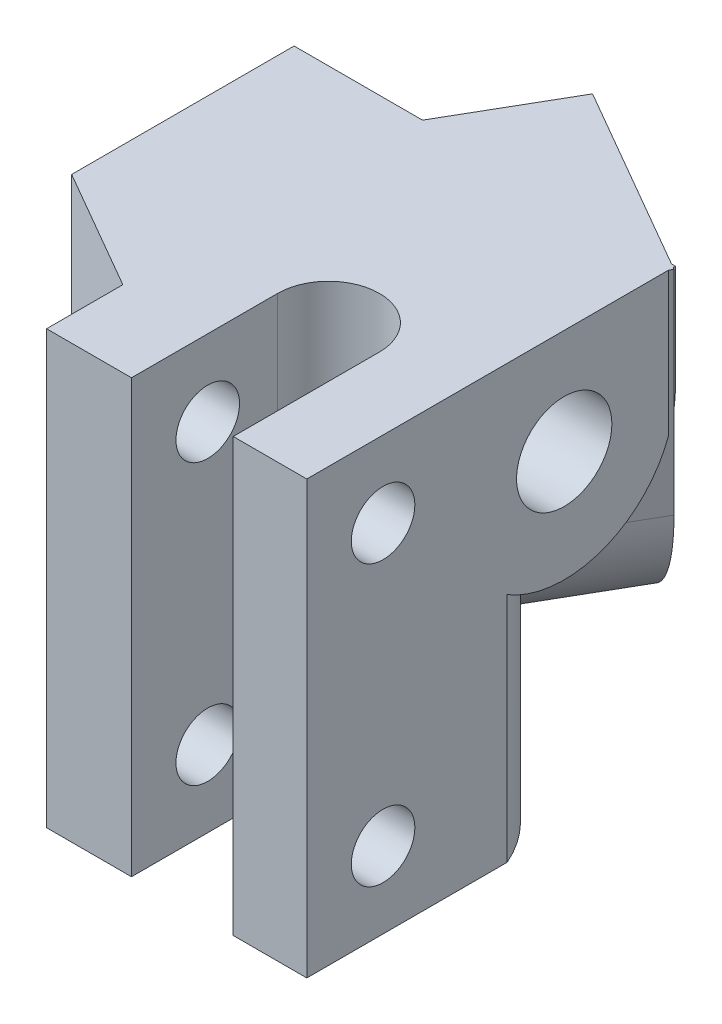
from build123d import *

# Parameters (mm, degrees)
SKETCH1_R               = 3.75
BOSS_EXTRUDE1_DEPTH     = 30
SKETCH2_R               = 3.75
BOSS_EXTRUDE2_DEPTH     = 30
CUT_EXTRUDE1_DEPTH      = 26.5000001
SKETCH4_W               = 5.792740578
SKETCH4_H               = 11.5
BOSS_EXTRUDE3_DEPTH     = 10
BOSS_EXTRUDE4_DEPTH     = 10
BOSS_EXTRUDE5_DEPTH     = 34
SKETCH5_R               = 2.5
CUT_EXTRUDE2_DEPTH      = 31.0000001
SKETCH7_R               = 3.75
CUT_EXTRUDE3_DEPTH      = 31.155444666
SKETCH8_R               = 3.75
CUT_EXTRUDE4_DEPTH      = 27.5
CUT_EXTRUDE4_DEPTH_BACK = 38.57772242


with BuildPart() as part:
    # Sketch1 → Boss-Extrude1 (new body)
    with BuildSketch(Plane(origin=(0, 0, 0), x_dir=(0, 0, -1), z_dir=(1, 0, 0))):
        with BuildLine():
            Line((-8.75, 0), (8.75, 0))
            Line((8.75, 0), (8.75, 8.25))
            ThreePointArc((8.75, 8.25), (0, 17), (-8.75, 8.25))
            Line((-8.75, 8.25), (-8.75, 0))
        make_face()
        with Locations((0, 8.25)):
            Circle(SKETCH1_R, mode=Mode.SUBTRACT)
    extrude(amount=BOSS_EXTRUDE1_DEPTH)

    # Sketch2 → Boss-Extrude2 (add)
    with BuildSketch(Plane(origin=(-3.788861142, 0, 6.5625), x_dir=(-0.866025404, 0, -0.5), z_dir=(0.5, 0, -0.866025404))):
        with BuildLine():
            Line((-4.375, 0), (-4.375, 16.75))
            ThreePointArc((-4.375, 16.75), (-13.125, 25.5), (-21.875, 16.75))
            Line((-21.875, 16.75), (-21.875, 0))
            Line((-21.875, 0), (-4.375, 0))
        make_face()
        with Locations((-13.125, 16.75)):
            Circle(SKETCH2_R, mode=Mode.SUBTRACT)
    extrude(amount=BOSS_EXTRUDE2_DEPTH)

    # Sketch3 → Cut-Extrude1 (cut, through all)
    with BuildSketch(Plane.XZ):
        with BuildLine():
            Line((24.207259422, 8.75), (24.207259422, 15.67820323))
            Line((24.207259422, 15.67820323), (16.207259422, 15.67820323))
            Line((16.207259422, 15.67820323), (16.207259422, 8.75))
            ThreePointArc((16.207259422, 8.75), (20.207259422, 4.75), (24.207259422, 8.75))
        make_face()
    extrude(amount=-CUT_EXTRUDE1_DEPTH, mode=Mode.SUBTRACT)

    # Sketch4 → Boss-Extrude3 (add)
    with BuildSketch(Plane.XZ):
        with Locations((27.103629711, 14.5)):
            Rectangle(SKETCH4_W, SKETCH4_H)
    extrude(amount=-BOSS_EXTRUDE3_DEPTH)

    # Sketch6 → Boss-Extrude4 (add)
    with BuildSketch(Plane.XZ):
        Polygon((16.207259422, 15.67820323), (16.207259422, 20.25), (9.526279442, 20.25), (9.526279442, 14.25), align=None)
    extrude(amount=-BOSS_EXTRUDE4_DEPTH)

    # Sketch9 → Boss-Extrude5 (add)
    with BuildSketch(Plane.XZ):
        with BuildLine():
            Line((16.207259422, 20.25), (9.526279442, 20.25))
            Line((9.526279442, 20.25), (9.526279442, 14.25))
            Line((9.526279442, 14.25), (9.526279442, 8.75))
            ThreePointArc((9.526279442, 8.75), (18.029270984, -1.706562518), (30, 4.485546307))
            Line((30, 4.485546307), (30, 20.25))
            Line((30, 20.25), (24.207259422, 20.25))
            Line((24.207259422, 20.25), (24.207259422, 8.75))
            ThreePointArc((24.207259422, 8.75), (20.207259422, 4.75), (16.207259422, 8.75))
            Line((16.207259422, 8.75), (16.207259422, 20.25))
        make_face()
    extrude(amount=-BOSS_EXTRUDE5_DEPTH)

    # Sketch5 → Cut-Extrude2 (cut, through all)
    with BuildSketch(Plane(origin=(30, 0, 0), x_dir=(0, 0, -1), z_dir=(1, 0, 0))):
        with Locations(Location((-14.25, 6, 0), (0, 0, 90))):  # turned: the seam where the file's is
            Circle(SKETCH5_R)
        with Locations(Location((-14.25, 28, 0), (0, 0, 180))):  # turned: the seam where the file's is
            Circle(SKETCH5_R)
    extrude(amount=-CUT_EXTRUDE2_DEPTH, mode=Mode.SUBTRACT)

    # Sketch7 → Cut-Extrude3 (cut, through all)
    with BuildSketch(Plane.ZY):
        with Locations(Location((0, 8.25, 0), (0, 0, 180))):  # turned: the seam where the file's is
            Circle(SKETCH7_R)
    extrude(amount=-CUT_EXTRUDE3_DEPTH, mode=Mode.SUBTRACT)

    # Sketch8 → Cut-Extrude4 (cut, two sides)
    with BuildSketch(Plane(origin=(-3.788861142, 0, 6.5625), x_dir=(0.866025404, 0, 0.5), z_dir=(-0.5, 0, 0.866025404))) as cut_extrude4_sk:
        with Locations(Location((13.125, 16.75, 0), (0, 0, 53.130102354))):  # turned: the seam where the file's is
            Circle(SKETCH8_R)
    extrude(amount=CUT_EXTRUDE4_DEPTH, mode=Mode.SUBTRACT)
    extrude(cut_extrude4_sk.sketch, amount=-CUT_EXTRUDE4_DEPTH_BACK, mode=Mode.SUBTRACT)


with BuildPart() as body_2:
    # Mirror1: mirrored copy
    add(part.part.mirror(Plane(origin=(30, 0, 8.75), x_dir=(0, 0, 1), z_dir=(0, 1, 0))))


solid = body_2.part
